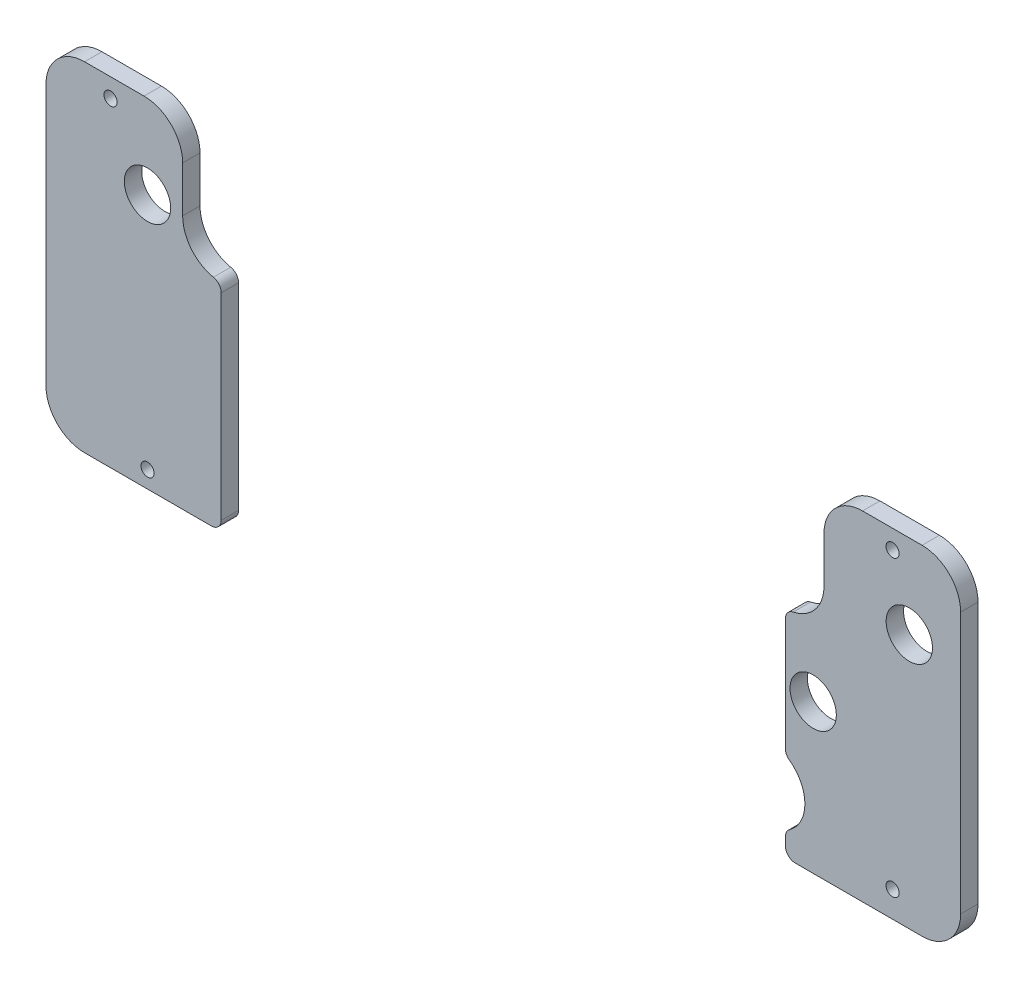
from build123d import *

# Parameters (mm, degrees)
BOSS_EXTRUDE1_DEPTH           = 4.5
BOSS_EXTRUDE1_2_DEPTH         = 4.5
SKETCH2_W                     = 1.7
SKETCH2_H                     = 4.5
M3_CLEARANCE_HOLE1_AT_2_COUNT = 2
M3_CLEARANCE_HOLE1_AT_2_PITCH = 197.4
M3_CLEARANCE_HOLE1_AT_3_COUNT = 2
M3_CLEARANCE_HOLE1_AT_3_PITCH = 37.104691078
M3_CLEARANCE_HOLE1_AT_4_COUNT = 2
M3_CLEARANCE_HOLE1_AT_4_PITCH = 206.806557667
SKETCH4_R                     = 6
CUT_EXTRUDE1_DEPTH            = 10
SKETCH5_W                     = 1.7
SKETCH5_H                     = 4.5
M3_CLEARANCE_HOLE2_AT_2_COUNT = 2
M3_CLEARANCE_HOLE2_AT_2_PITCH = 76.125208572
M3_CLEARANCE_HOLE2_AT_3_COUNT = 2
M3_CLEARANCE_HOLE2_AT_3_PITCH = 202.646007696


with BuildPart() as part:
    # Sketch1 → Boss-Extrude1 (new body)
    with BuildSketch(Plane.XY):
        with BuildLine():
            Line((83.222758289, -305.87735135), (83.222758289, -335.087441965))
            ThreePointArc((83.222758289, -335.087441965), (83.502426869, -336.246105795), (84.279846376, -337.149618548))
            ThreePointArc((84.279846376, -337.149618548), (88.270952069, -344.935502047), (84.279846376, -352.721385546))
            ThreePointArc((84.279846376, -352.721385546), (83.502426869, -353.624898299), (83.222758289, -354.78356213))
            Line((83.222758289, -354.78356213), (83.222758289, -356.924720764))
            ThreePointArc((83.222758289, -356.924720764), (83.966707064, -358.720771988), (85.762758289, -359.464720764))
            Line((85.762758289, -359.464720764), (118.627293893, -359.464720764))
            ThreePointArc((118.627293893, -359.464720764), (125.698361705, -356.535788576), (128.627293893, -349.464720764))
            Line((128.627293893, -349.464720764), (128.627293893, -281.718782294))
            ThreePointArc((128.627293893, -281.718782294), (125.698361705, -274.647714482), (118.627293893, -271.718782294))
            Line((118.627293893, -271.718782294), (103.222758289, -271.718782294))
            ThreePointArc((103.222758289, -271.718782294), (96.151690477, -274.647714482), (93.222758289, -281.718782294))
            Line((93.222758289, -281.718782294), (93.222758289, -293.597286204))
            ThreePointArc((93.222758289, -293.597286204), (90.976956616, -299.911746457), (85.24827663, -303.390001631))
            ThreePointArc((85.24827663, -303.390001631), (83.793191913, -304.273478446), (83.222758289, -305.87735135))
        make_face()
    extrude(amount=BOSS_EXTRUDE1_DEPTH)

    # Sketch2 → M3 Clearance Hole1 (revolve, cut)
    with BuildSketch(Plane(origin=(115.327293893, -293.415681156, 4.5), x_dir=(0, -1, 0), z_dir=(1, 0, 0))):
        with Locations((0.85, 2.25)):
            Rectangle(SKETCH2_W, SKETCH2_H)
    m3_clearance_hole1 = revolve(axis=Axis((115.327293893, -293.415681156, 10.85), (0, 0, -1)), mode=Mode.SUBTRACT)

    # M3 Clearance Hole1 at 3: M3 Clearance Hole1 ×2
    with Locations(*[Vector(-0.671343684, -0.741146179, 0) * (i * M3_CLEARANCE_HOLE1_AT_3_PITCH) for i in range(1, M3_CLEARANCE_HOLE1_AT_3_COUNT)]):
        add(m3_clearance_hole1, mode=Mode.SUBTRACT)


with BuildPart() as body_2:
    # Sketch1 → Boss-Extrude1 2 (new body)
    with BuildSketch(Plane.XY):
        with BuildLine():
            Line((-62.968170503, -305.87735135), (-62.968170503, -356.924720764))
            ThreePointArc((-62.968170503, -356.924720764), (-63.712119279, -358.720771988), (-65.508170503, -359.464720764))
            Line((-65.508170503, -359.464720764), (-98.372706107, -359.464720764))
            ThreePointArc((-98.372706107, -359.464720764), (-105.443773919, -356.535788576), (-108.372706107, -349.464720764))
            Line((-108.372706107, -349.464720764), (-108.372706107, -281.718782294))
            ThreePointArc((-108.372706107, -281.718782294), (-105.443773919, -274.647714482), (-98.372706107, -271.718782294))
            Line((-98.372706107, -271.718782294), (-82.968170503, -271.718782294))
            ThreePointArc((-82.968170503, -271.718782294), (-75.897102691, -274.647714482), (-72.968170503, -281.718782294))
            Line((-72.968170503, -281.718782294), (-72.968170503, -293.597286204))
            ThreePointArc((-72.968170503, -293.597286204), (-70.722368831, -299.911746457), (-64.993688844, -303.390001631))
            ThreePointArc((-64.993688844, -303.390001631), (-63.538604128, -304.273478446), (-62.968170503, -305.87735135))
        make_face()
    extrude(amount=BOSS_EXTRUDE1_2_DEPTH)

    # M3 Clearance Hole1 at 2: M3 Clearance Hole1 ×2
    with Locations(*[(-i * M3_CLEARANCE_HOLE1_AT_2_PITCH, 0, 0) for i in range(1, M3_CLEARANCE_HOLE1_AT_2_COUNT)]):
        add(m3_clearance_hole1, mode=Mode.SUBTRACT)

    # M3 Clearance Hole1 at 4: M3 Clearance Hole1 ×2
    with Locations(*[Vector(-0.954515187, -0.298162302, 0) * (i * M3_CLEARANCE_HOLE1_AT_4_PITCH) for i in range(1, M3_CLEARANCE_HOLE1_AT_4_COUNT)]):
        add(m3_clearance_hole1, mode=Mode.SUBTRACT)


with BuildPart() as cut_extrude1_tool:
    # Sketch4 → Cut-Extrude1 (new body)
    with BuildSketch(Plane.XY.offset(4.5)):
        with Locations((115.327293893, -293.415681156)):
            Circle(SKETCH4_R)
        with Locations((90.417293893, -320.915681156)):
            Circle(SKETCH4_R)
        with Locations((-82.072706107, -293.415681156)):
            Circle(SKETCH4_R)
    extrude(amount=-CUT_EXTRUDE1_DEPTH)


with BuildPart() as part_1:
    add(part.part)

    # Cut-Extrude1: cut by cut_extrude1_tool
    add(cut_extrude1_tool.part, mode=Mode.SUBTRACT)

    # Sketch5 → M3 Clearance Hole2 (revolve, cut)
    with BuildSketch(Plane(origin=(110.992072638, -276.597499362, 4.5), x_dir=(0, -1, 0), z_dir=(1, 0, 0))):
        with Locations((0.85, 2.25)):
            Rectangle(SKETCH5_W, SKETCH5_H)
    m3_clearance_hole2 = revolve(axis=Axis((110.992072638, -276.597499362, 10.85), (0, 0, -1)), mode=Mode.SUBTRACT)

    # M3 Clearance Hole2 at 2: M3 Clearance Hole2 ×2
    with Locations(*[(0, -i * M3_CLEARANCE_HOLE2_AT_2_PITCH, 0) for i in range(1, M3_CLEARANCE_HOLE2_AT_2_COUNT)]):
        add(m3_clearance_hole2, mode=Mode.SUBTRACT)


with BuildPart() as body_2_1:
    add(body_2.part)

    # Cut-Extrude1: cut by cut_extrude1_tool
    add(cut_extrude1_tool.part, mode=Mode.SUBTRACT)

    # M3 Clearance Hole2 at 3: M3 Clearance Hole2 ×2
    with Locations(*[(-i * M3_CLEARANCE_HOLE2_AT_3_PITCH, 0, 0) for i in range(1, M3_CLEARANCE_HOLE2_AT_3_COUNT)]):
        add(m3_clearance_hole2, mode=Mode.SUBTRACT)


solid = Compound([part_1.part, body_2_1.part])
